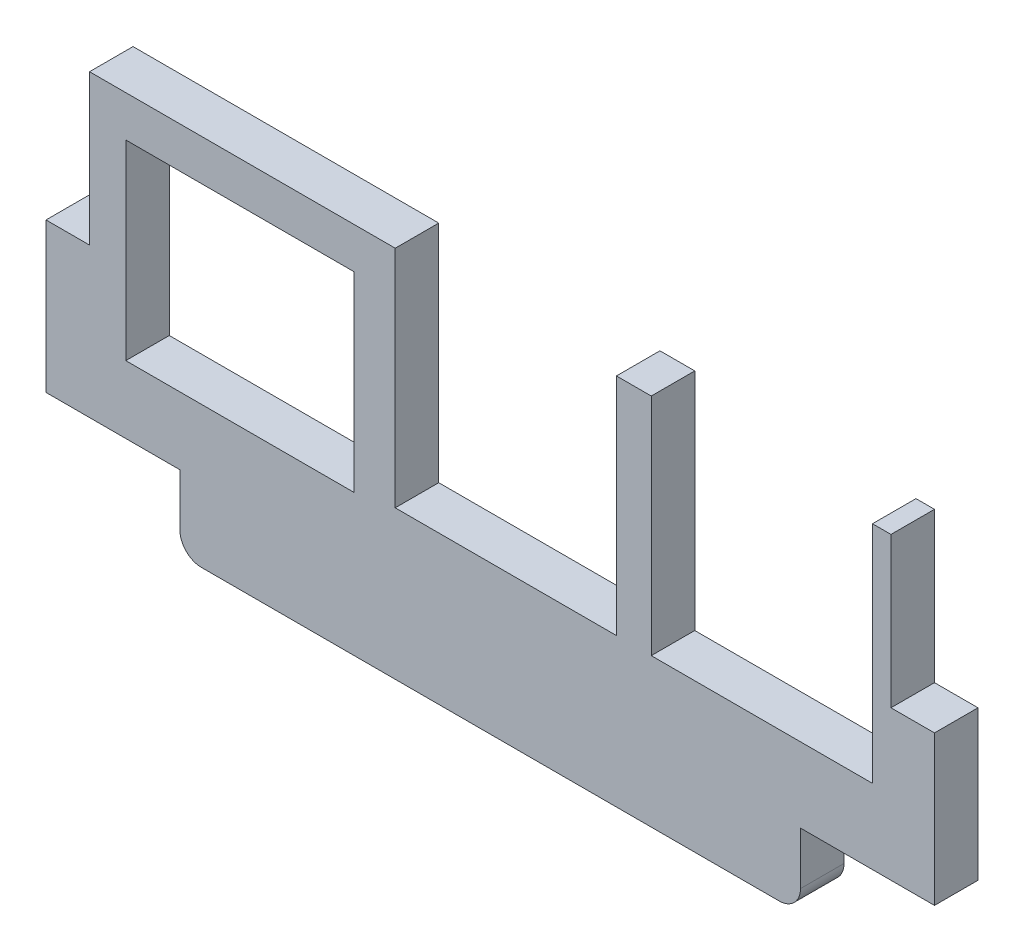
from build123d import *

# Parameters (mm, degrees)
MODEL_W             = 16.001999145
MODEL_H             = 13.385799247
BOSS_EXTRUDE1_DEPTH = 3.048


with BuildPart() as part:
    # Model → Boss-Extrude1 (new body)
    with BuildSketch(Plane.XY):
        with BuildLine():
            Line((3.047999926, 15.63479994), (0, 15.63479994))
            Line((0, 15.63479994), (0, 5.17))
            Line((0, 5.17), (9.382999755, 5.17))
            Line((9.382999755, 5.17), (9.382999755, 1.5))
            ThreePointArc((9.382999755, 1.5), (9.822339583, 0.439339828), (10.882999755, 0))
            Line((10.882999755, 0), (51.346999833, 0))
            ThreePointArc((51.346999833, 0), (52.407660005, 0.439339828), (52.846999833, 1.5))
            Line((52.846999833, 1.5), (52.846999833, 5.17))
            Line((52.846999833, 5.17), (62.229999341, 5.17))
            Line((62.229999341, 5.17), (62.229999341, 15.63479994))
            Line((62.229999341, 15.63479994), (59.182000346, 15.63479994))
            Line((59.182000346, 15.63479994), (59.182000346, 26.150399451))
            Line((59.182000346, 26.150399451), (57.886601426, 26.150399451))
            Line((57.886601426, 26.150399451), (57.886601426, 10.402400144))
            Line((57.886601426, 10.402400144), (42.392601259, 10.402400144))
            Line((42.392601259, 10.402400144), (42.392601259, 26.150399451))
            Line((42.392601259, 26.150399451), (39.954201318, 26.150399451))
            Line((39.954201318, 26.150399451), (39.954201318, 10.402400144))
            Line((39.954201318, 10.402400144), (24.460199289, 10.402400144))
            Line((24.460199289, 10.402400144), (24.460199289, 26.150399451))
            Line((24.460199289, 26.150399451), (3.047999926, 26.150399451))
            Line((3.047999926, 26.150399451), (3.047999926, 15.63479994))
        make_face()
        with Locations((13.588999515, 16.587299626)):
            Rectangle(MODEL_W, MODEL_H, mode=Mode.SUBTRACT)
    extrude(amount=BOSS_EXTRUDE1_DEPTH)


solid = part.part
